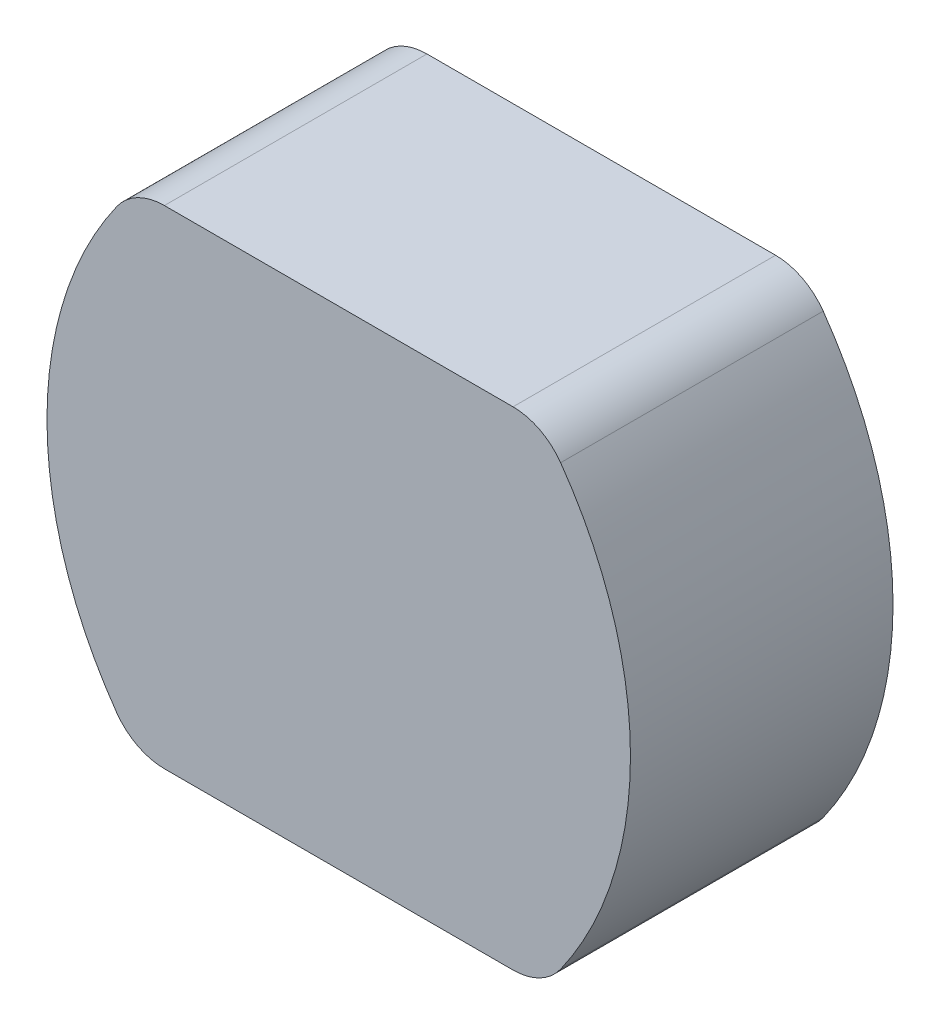
from build123d import *

# Parameters (mm, degrees)
BOSS_EXTRUDE1_DEPTH = 9
FILLET2_R           = 2
FILLET3_R           = 2


with BuildPart() as part:
    # Sketch1 → Boss-Extrude1 (new body)
    with BuildSketch(Plane.XY):
        with BuildLine():
            ThreePointArc((-6.955420634, 8.36), (-9.215164105, 4.44856897), (-10, 0))
            Line((-10, 0), (10, 0))
            ThreePointArc((10, 0), (9.215164105, 4.44856897), (6.955420634, 8.36))
            Line((6.955420634, 8.36), (-6.955420634, 8.36))
        make_face()
        with BuildLine():
            Line((10, 0), (-10, 0))
            ThreePointArc((-10, 0), (-9.215164105, -4.44856897), (-6.955420634, -8.36))
            Line((-6.955420634, -8.36), (6.955420634, -8.36))
            ThreePointArc((6.955420634, -8.36), (9.215164105, -4.44856897), (10, 0))
        make_face()
    extrude(amount=BOSS_EXTRUDE1_DEPTH)

    # Fillet2
    fillet2_edges = [part.edges().sort_by_distance(p)[0] for p in [
        (-6.955420634, 8.36, 4.5),
        (6.955420634, 8.36, 4.5),
    ]]
    fillet(fillet2_edges, radius=FILLET2_R)

    # Fillet3
    fillet3_edges = [part.edges().sort_by_distance(p)[0] for p in [
        (6.955420634, -8.36, 4.5),
        (-6.955420634, -8.36, 4.5),
    ]]
    fillet(fillet3_edges, radius=FILLET3_R)


solid = part.part
